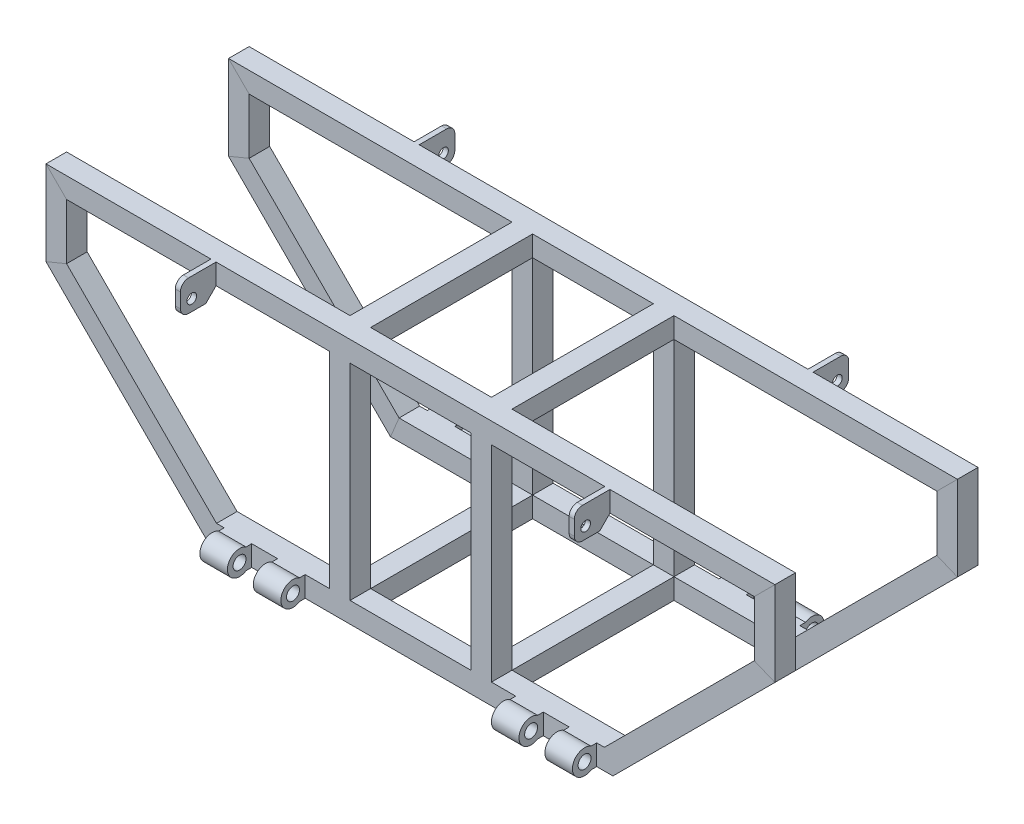
from build123d import *

# Parameters (mm, degrees)
SKETCH8_W               = 25.4
SKETCH8_H               = 25.4
SKETCH8_W_2             = 23
SKETCH8_H_2             = 23
SKETCH10_R              = 8
BOSS_EXTRUDE2_DEPTH     = 140
SKETCH11_W              = 32
SKETCH11_H              = 30
SKETCH11_W_2            = 20
CUT_EXTRUDE1_DEPTH      = 80
CUT_EXTRUDE1_DEPTH_BACK = 5
SKETCH12_R              = 8
BOSS_EXTRUDE3_DEPTH     = 140
SKETCH13_W              = 20
SKETCH13_H              = 30
SKETCH13_W_2            = 32
CUT_EXTRUDE2_DEPTH      = 66
CUT_EXTRUDE2_DEPTH_BACK = 11
SKETCH18_W              = 25.4
SKETCH18_H              = 25.4
SKETCH18_W_2            = 23
SKETCH18_H_2            = 23
BOSS_EXTRUDE8_DEPTH     = 100
BOSS_EXTRUDE9_REACH     = 281.2
SKETCH17_W              = 25.4
SKETCH17_H              = 25.4
SKETCH17_W_2            = 23
SKETCH17_H_2            = 23
SKETCH14_R              = 6
BOSS_EXTRUDE4_DEPTH     = 6.35


with BuildPart() as part:
    # Sweep3: sweep along a path in Sketch9
    with BuildLine(Plane.XY) as sweep3_path:
        Line((-450, -130), (-250, -330))
        Line((-250, -330), (250, -330))
        Line((250, -330), (450, -130))
        Line((450, -130), (450, -25.4))
        Line((450, -25.4), (-450, -25.4))
        Line((-450, -25.4), (-450, -130))
    # Sketch8 → Sweep3 (sweep)
    with BuildSketch(Plane(origin=(0, 0, 0), x_dir=(0, 0, -1), z_dir=(1, 0, 0))):
        with Locations((-112.7, -317.3)):
            Rectangle(SKETCH8_W, SKETCH8_H)
        with Locations((-112.7, -317.3)):
            Rectangle(SKETCH8_W_2, SKETCH8_H_2, mode=Mode.SUBTRACT)
    sweep(path=sweep3_path.line, transition=Transition.RIGHT)

    # Sketch10 → Boss-Extrude2 (add)
    with BuildSketch(Plane.ZY.offset(110)):
        with BuildLine():
            Line((125.4, -304.6), (132.418145579, -304.6))
            ThreePointArc((132.418145579, -304.6), (155.4, -317.3), (132.418145579, -330))
            Line((132.418145579, -330), (125.4, -330))
            Line((125.4, -330), (125.4, -304.6))
        make_face()
        with Locations((140.4, -317.3)):
            Circle(SKETCH10_R, mode=Mode.SUBTRACT)
    extrude(amount=BOSS_EXTRUDE2_DEPTH)

    # Sketch11 → Cut-Extrude1 (cut, two sides)
    with BuildSketch(Plane(origin=(0, -355.4, 0), x_dir=(1, 0, 0), z_dir=(0, 1, 0))) as cut_extrude1_sk:
        with Locations((-180, -140.4)):
            Rectangle(SKETCH11_W, SKETCH11_H)
        with Locations((-120, -140.4)):
            Rectangle(SKETCH11_W_2, SKETCH11_H)
        with Locations((-240, -140.4)):
            Rectangle(SKETCH11_W_2, SKETCH11_H)
    extrude(amount=CUT_EXTRUDE1_DEPTH, mode=Mode.SUBTRACT)
    extrude(cut_extrude1_sk.sketch, amount=-CUT_EXTRUDE1_DEPTH_BACK, mode=Mode.SUBTRACT)

    # Sketch12 → Boss-Extrude3 (add)
    with BuildSketch(Plane(origin=(110, 0, 0), x_dir=(0, 0, -1), z_dir=(1, 0, 0))):
        with BuildLine():
            Line((-125.4, -304.6), (-132.418145579, -304.6))
            ThreePointArc((-132.418145579, -304.6), (-155.4, -317.3), (-132.418145579, -330))
            Line((-132.418145579, -330), (-125.4, -330))
            Line((-125.4, -330), (-125.4, -304.6))
        make_face()
        with Locations((-140.4, -317.3)):
            Circle(SKETCH12_R, mode=Mode.SUBTRACT)
    extrude(amount=BOSS_EXTRUDE3_DEPTH)

    # Sketch13 → Cut-Extrude2 (cut, two sides)
    with BuildSketch(Plane(origin=(0, -355.4, 0), x_dir=(1, 0, 0), z_dir=(0, 1, 0))) as cut_extrude2_sk:
        with Locations((240, -140.4)):
            Rectangle(SKETCH13_W, SKETCH13_H)
        with Locations((180, -140.4)):
            Rectangle(SKETCH13_W_2, SKETCH13_H)
        with Locations((120, -140.4)):
            Rectangle(SKETCH13_W, SKETCH13_H)
    extrude(amount=CUT_EXTRUDE2_DEPTH, mode=Mode.SUBTRACT)
    extrude(cut_extrude2_sk.sketch, amount=-CUT_EXTRUDE2_DEPTH_BACK, mode=Mode.SUBTRACT)

    # Sketch18 → Boss-Extrude8 (add)
    with BuildSketch(Plane(origin=(0, 0, 100), x_dir=(-1, 0, 0), z_dir=(0, 0, -1))):
        with Locations((-87.3, -38.1)):
            Rectangle(SKETCH18_W, SKETCH18_H)
        with Locations((-87.3, -38.1)):
            Rectangle(SKETCH18_W_2, SKETCH18_H_2, mode=Mode.SUBTRACT)
        with Locations((87.3, -38.1)):
            Rectangle(SKETCH18_W, SKETCH18_H)
        with Locations((87.3, -38.1)):
            Rectangle(SKETCH18_W_2, SKETCH18_H_2, mode=Mode.SUBTRACT)
        with Locations((-87.3, -317.3)):
            Rectangle(SKETCH18_W, SKETCH18_H)
        with Locations((-87.3, -317.3)):
            Rectangle(SKETCH18_W_2, SKETCH18_H_2, mode=Mode.SUBTRACT)
        with Locations((87.3, -317.3)):
            Rectangle(SKETCH18_W, SKETCH18_H)
        with Locations((87.3, -317.3)):
            Rectangle(SKETCH18_W_2, SKETCH18_H_2, mode=Mode.SUBTRACT)
    extrude(amount=BOSS_EXTRUDE8_DEPTH)

    # Mirror10: part across plane


with BuildPart() as part_1:
    add(part.part)
    add(part.part.mirror(Plane.XY))

    # Sketch17 → Boss-Extrude9 (add, up to next)
    with BuildSketch(Plane(origin=(0, -304.6, 0), x_dir=(1, 0, 0), z_dir=(0, 1, 0)), mode=Mode.PRIVATE) as boss_extrude9_sk1:
        with Locations((-87.3, -112.7)):
            Rectangle(SKETCH17_W, SKETCH17_H)
        with Locations((-87.3, -112.7)):
            Rectangle(SKETCH17_W_2, SKETCH17_H_2, mode=Mode.SUBTRACT)
    boss_extrude9_tool1 = extrude(boss_extrude9_sk1.sketch, amount=BOSS_EXTRUDE9_REACH, mode=Mode.PRIVATE) - part_1.part
    add(boss_extrude9_tool1.solids().sort_by_distance((-87.3, -304.6, 125.04079))[0])
    # Sketch17 → Boss-Extrude9 (add, up to next)
    with BuildSketch(Plane(origin=(0, -304.6, 0), x_dir=(1, 0, 0), z_dir=(0, 1, 0)), mode=Mode.PRIVATE) as boss_extrude9_sk2:
        with Locations((87.3, -112.7)):
            Rectangle(SKETCH17_W, SKETCH17_H)
        with Locations((87.3, -112.7)):
            Rectangle(SKETCH17_W_2, SKETCH17_H_2, mode=Mode.SUBTRACT)
    boss_extrude9_tool2 = extrude(boss_extrude9_sk2.sketch, amount=BOSS_EXTRUDE9_REACH, mode=Mode.PRIVATE) - part_1.part
    add(boss_extrude9_tool2.solids().sort_by_distance((87.3, -304.6, 125.04079))[0])
    # Sketch17 → Boss-Extrude9 (add, up to next)
    with BuildSketch(Plane(origin=(0, -304.6, 0), x_dir=(1, 0, 0), z_dir=(0, 1, 0)), mode=Mode.PRIVATE) as boss_extrude9_sk3:
        with Locations((87.3, 112.7)):
            Rectangle(SKETCH17_W, SKETCH17_H)
        with Locations((87.3, 112.7)):
            Rectangle(SKETCH17_W_2, SKETCH17_H_2, mode=Mode.SUBTRACT)
    boss_extrude9_tool3 = extrude(boss_extrude9_sk3.sketch, amount=BOSS_EXTRUDE9_REACH, mode=Mode.PRIVATE) - part_1.part
    add(boss_extrude9_tool3.solids().sort_by_distance((99.64079, -304.6, -112.7))[0])
    # Sketch17 → Boss-Extrude9 (add, up to next)
    with BuildSketch(Plane(origin=(0, -304.6, 0), x_dir=(1, 0, 0), z_dir=(0, 1, 0)), mode=Mode.PRIVATE) as boss_extrude9_sk4:
        with Locations((-87.3, 112.7)):
            Rectangle(SKETCH17_W, SKETCH17_H)
        with Locations((-87.3, 112.7)):
            Rectangle(SKETCH17_W_2, SKETCH17_H_2, mode=Mode.SUBTRACT)
    boss_extrude9_tool4 = extrude(boss_extrude9_sk4.sketch, amount=BOSS_EXTRUDE9_REACH, mode=Mode.PRIVATE) - part_1.part
    add(boss_extrude9_tool4.solids().sort_by_distance((-74.95921, -304.6, -112.7))[0])

    # Sketch14 → Boss-Extrude4 (add)
    with BuildSketch(Plane.ZY.offset(-240)):
        with BuildLine():
            Line((125.4, -25.4), (125.4, -50.8))
            Line((125.4, -50.8), (138.1, -63.5))
            Line((138.1, -63.5), (159.4, -63.5))
            ThreePointArc((159.4, -63.5), (166.471067812, -60.571067812), (169.4, -53.5))
            Line((169.4, -53.5), (169.4, -35.4))
            ThreePointArc((169.4, -35.4), (166.471067812, -28.328932188), (159.4, -25.4))
            Line((159.4, -25.4), (125.4, -25.4))
        make_face()
        with Locations((155.4, -49.5)):
            Circle(SKETCH14_R, mode=Mode.SUBTRACT)
        with BuildLine():
            Line((-159.4, -25.4), (-125.4, -25.4))
            Line((-125.4, -25.4), (-125.4, -50.8))
            Line((-125.4, -50.8), (-138.1, -63.5))
            Line((-138.1, -63.5), (-159.4, -63.5))
            ThreePointArc((-159.4, -63.5), (-166.471067812, -60.571067812), (-169.4, -53.5))
            Line((-169.4, -53.5), (-169.4, -35.4))
            ThreePointArc((-169.4, -35.4), (-166.471067812, -28.328932188), (-159.4, -25.4))
        make_face()
        with Locations((-155.4, -49.5)):
            Circle(SKETCH14_R, mode=Mode.SUBTRACT)
    boss_extrude4 = extrude(amount=-BOSS_EXTRUDE4_DEPTH)

    # Mirror11: Boss-Extrude4 across plane
    add(boss_extrude4.mirror(Plane(origin=(0, 0, 0), x_dir=(0, 0, 1), z_dir=(1, 0, 0))))


solid = part_1.part
